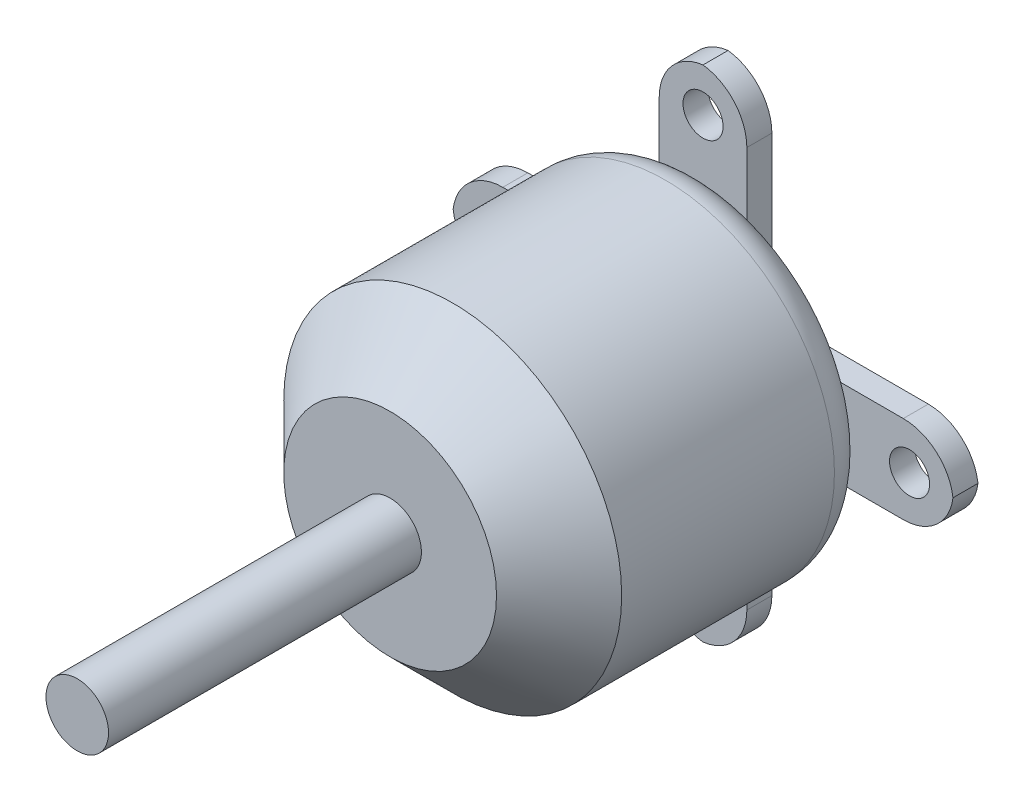
from build123d import *

# Parameters (mm, degrees)
SKETCH1_R           = 13.5
BOSS_EXTRUDE1_DEPTH = 25
SKETCH2_R           = 2.5
BOSS_EXTRUDE2_DEPTH = 25
FILLET1_R           = 3
CHAMFER1_SIZE       = 5
SKETCH3_R           = 1.6
BOSS_EXTRUDE3_DEPTH = 2
SKETCH4_R           = 4
CUT_EXTRUDE1_DEPTH  = 2


with BuildPart() as part:
    # Sketch1 → Boss-Extrude1 (new body)
    with BuildSketch(Plane.XY):
        Circle(SKETCH1_R)
    extrude(amount=BOSS_EXTRUDE1_DEPTH)

    # Sketch2 → Boss-Extrude2 (add)
    with BuildSketch(Plane.XY.offset(25)):
        Circle(SKETCH2_R)
    extrude(amount=BOSS_EXTRUDE2_DEPTH)

    # Fillet1
    fillet1_edges = [part.edges().sort_by_distance(p)[0] for p in [
        (-13.5, 0, 0),
    ]]
    fillet(fillet1_edges, radius=FILLET1_R)

    # Chamfer1
    chamfer1_edges = [part.edges().sort_by_distance(p)[0] for p in [
        (-13.5, 0, 25),
    ]]
    chamfer(chamfer1_edges, length=CHAMFER1_SIZE)

    # Sketch3 → Boss-Extrude3 (add)
    with BuildSketch(Plane(origin=(0, 0, 0), x_dir=(-1, 0, 0), z_dir=(0, 0, -1))):
        with BuildLine():
            Line((-3.5, -7.5), (-3.5, -16))
            ThreePointArc((-3.5, -16), (-2.5, -18.645751311), (0, -19.968626967))
            ThreePointArc((0, -19.968626967), (2.5, -18.645751311), (3.5, -16))
            Line((3.5, -16), (3.5, -7.5))
            ThreePointArc((3.5, -7.5), (4.671572875, -4.671572875), (7.5, -3.5))
            Line((7.5, -3.5), (16, -3.5))
            ThreePointArc((16, -3.5), (18.645751311, -2.5), (19.968626967, 0))
            ThreePointArc((19.968626967, 0), (18.645751311, 2.5), (16, 3.5))
            Line((16, 3.5), (7.5, 3.5))
            ThreePointArc((7.5, 3.5), (4.671572875, 4.671572875), (3.5, 7.5))
            Line((3.5, 7.5), (3.5, 16))
            ThreePointArc((3.5, 16), (2.5, 18.645751311), (0, 19.968626967))
            ThreePointArc((0, 19.968626967), (-2.5, 18.645751311), (-3.5, 16))
            Line((-3.5, 16), (-3.5, 7.5))
            ThreePointArc((-3.5, 7.5), (-4.671572875, 4.671572875), (-7.5, 3.5))
            Line((-7.5, 3.5), (-16, 3.5))
            ThreePointArc((-16, 3.5), (-18.645751311, 2.5), (-19.968626967, 0))
            ThreePointArc((-19.968626967, 0), (-18.645751311, -2.5), (-16, -3.5))
            Line((-16, -3.5), (-7.5, -3.5))
            ThreePointArc((-7.5, -3.5), (-4.671572875, -4.671572875), (-3.5, -7.5))
        make_face()
        with Locations((-16.5, 0)):
            Circle(SKETCH3_R, mode=Mode.SUBTRACT)
        with Locations((0, 16.5)):
            Circle(SKETCH3_R, mode=Mode.SUBTRACT)
        with Locations((16.5, 0)):
            Circle(SKETCH3_R, mode=Mode.SUBTRACT)
        with Locations((0, -16.5)):
            Circle(SKETCH3_R, mode=Mode.SUBTRACT)
    extrude(amount=BOSS_EXTRUDE3_DEPTH)

    # Sketch4 → Cut-Extrude1 (cut)
    with BuildSketch(Plane(origin=(0, 0, -2), x_dir=(-1, 0, 0), z_dir=(0, 0, -1))):
        Circle(SKETCH4_R)
    extrude(amount=-CUT_EXTRUDE1_DEPTH, mode=Mode.SUBTRACT)


solid = part.part
